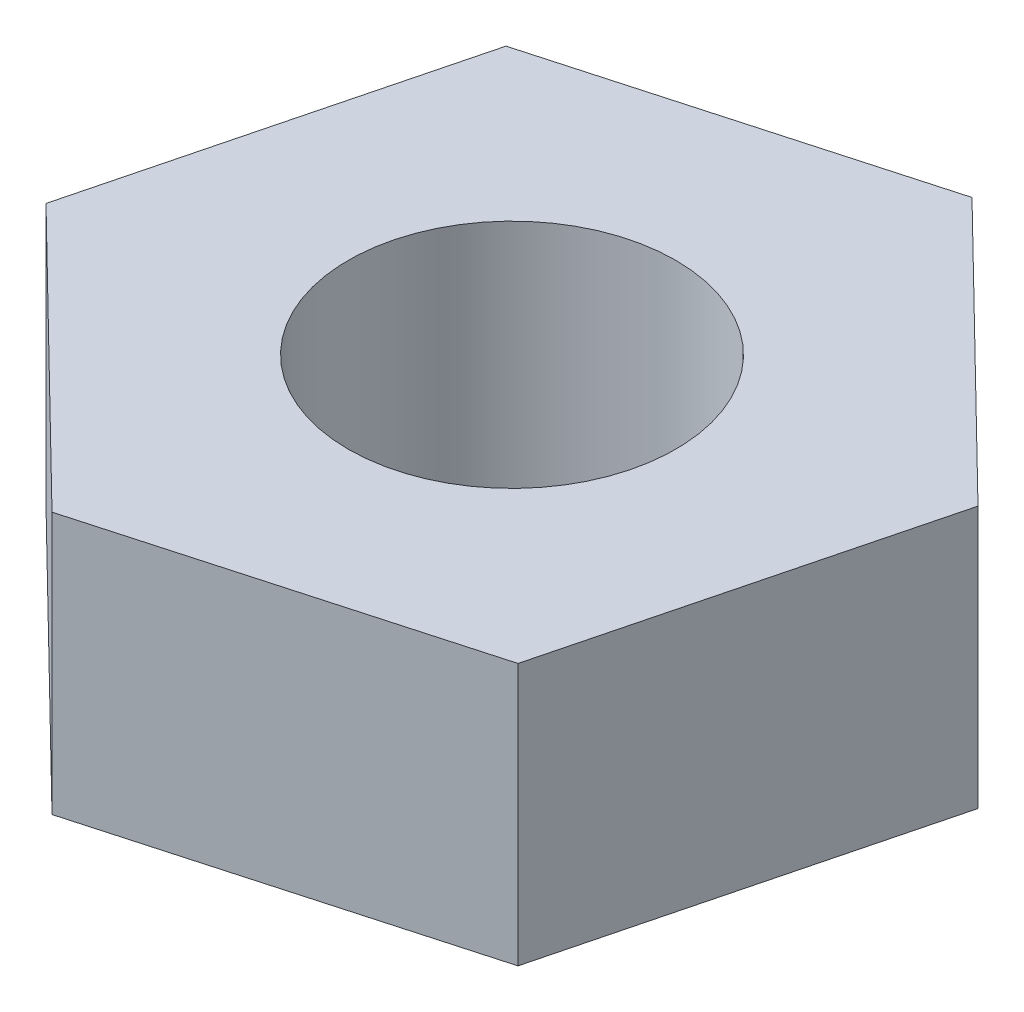
from build123d import *

# Parameters (mm, degrees)
SKETCH_1_R      = 1
EXTRUDE_1_DEPTH = 1.6


with BuildPart() as part:
    # 草图1 → 凸台-拉伸1 (new body)
    with BuildSketch(Plane(origin=(0, 0, 0), x_dir=(1, 0, 0), z_dir=(0, 1, 0))):
        Polygon((1.651237171, -1.614543012), (2.22385385, 0.622741832), (0.572616678, 2.237284844), (-1.651237171, 1.614543012), (-2.22385385, -0.622741832), (-0.572616678, -2.237284844), align=None)
        Circle(SKETCH_1_R, mode=Mode.SUBTRACT)
    extrude(amount=EXTRUDE_1_DEPTH)


solid = part.part
